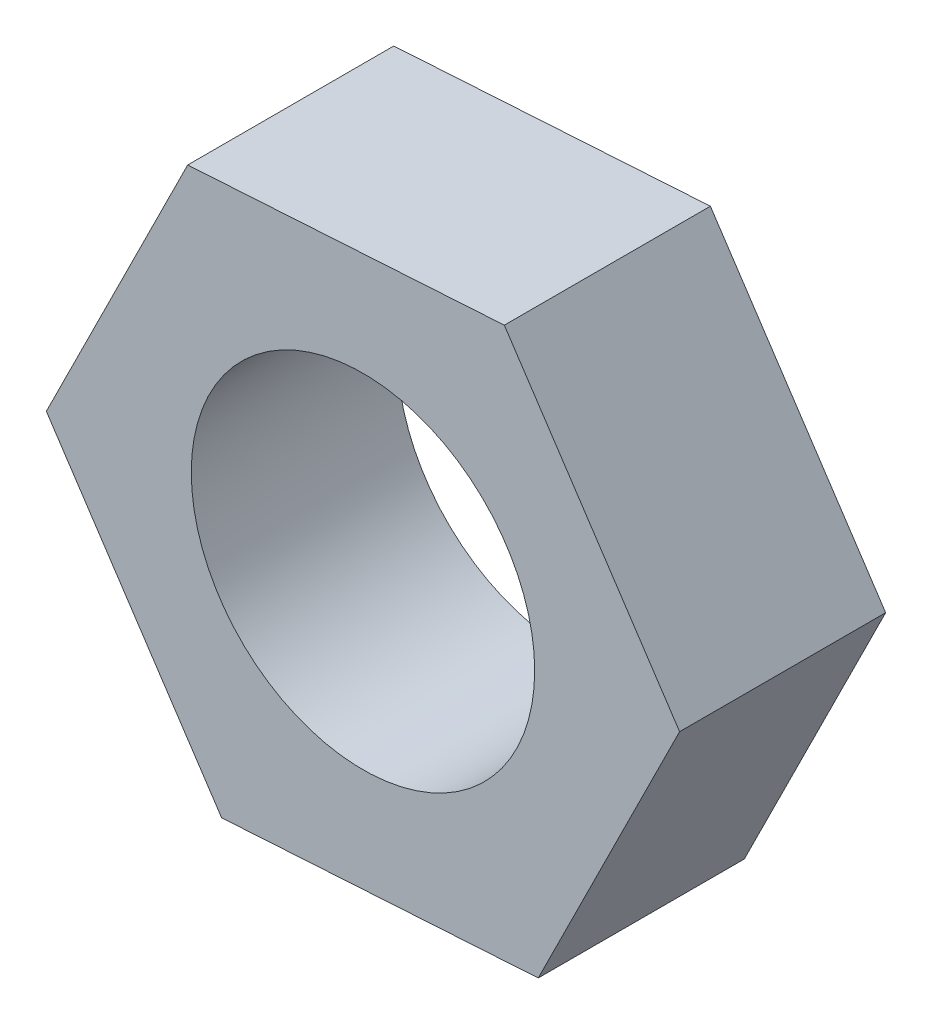
from build123d import *

# Parameters (mm, degrees)
EXTRUDE_1_DEPTH     = 3
CUT_EXTRUDE_1_REACH = 5
SKETCH_2_R          = 2.5


with BuildPart() as part:
    # 草圖1 → 填料-伸長1 (new body)
    with BuildSketch(Plane.XY):
        Polygon((2.058046104, 4.134946138), (-2.551945347, 3.849793278), (-4.609991451, -0.285152861), (-2.058046104, -4.134946138), (2.551945347, -3.849793278), (4.609991451, 0.285152861), align=None)
    extrude(amount=EXTRUDE_1_DEPTH)

    # 草圖2 → 除料-伸長1 (cut, up to next)
    with BuildSketch(Plane.XY.offset(3), mode=Mode.PRIVATE) as cut_extrude_1_sk1:
        Circle(SKETCH_2_R)
    cut_extrude_1_tool1 = extrude(cut_extrude_1_sk1.sketch, amount=-CUT_EXTRUDE_1_REACH, mode=Mode.PRIVATE) & part.part
    add(cut_extrude_1_tool1.solids().sort_by_distance((0, 0, 3))[0], mode=Mode.SUBTRACT)


solid = part.part
